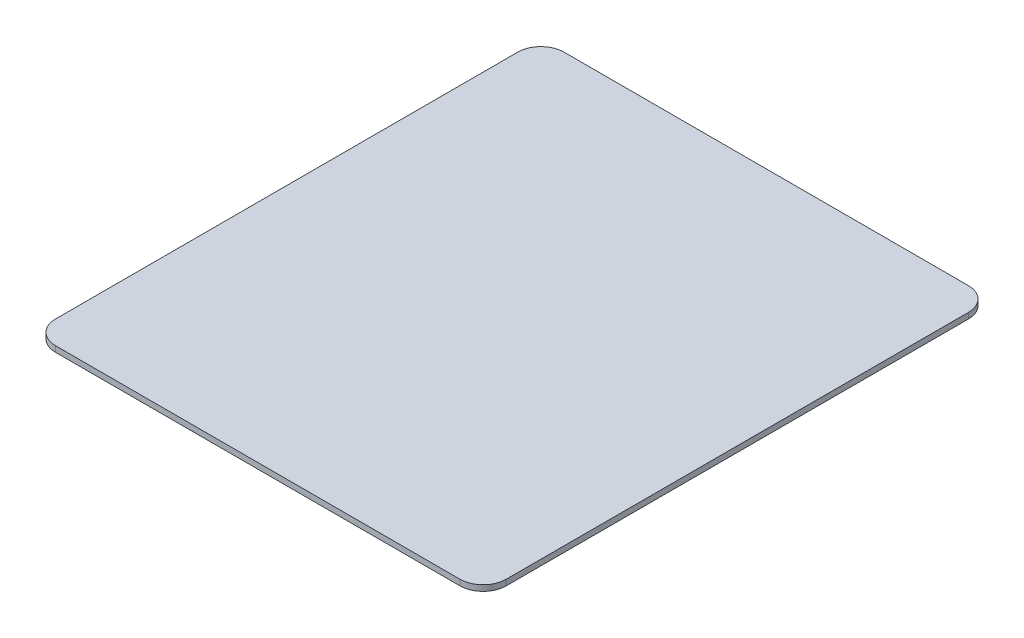
from build123d import *

# Parameters (mm, degrees)
BOSS_EXTRUDE1_DEPTH = 0.5


with BuildPart() as part:
    # Sketch3 → Boss-Extrude1 (new body)
    with BuildSketch(Plane(origin=(0, 0, 0), x_dir=(1, 0, 0), z_dir=(0, 1, 0))):
        with BuildLine():
            Line((-17.5, -22), (17.5, -22))
            ThreePointArc((17.5, -22), (18.914213562, -21.414213562), (19.5, -20))
            Line((19.5, -20), (19.5, 20))
            ThreePointArc((19.5, 20), (18.914213562, 21.414213562), (17.5, 22))
            Line((17.5, 22), (-17.5, 22))
            ThreePointArc((-17.5, 22), (-18.914213562, 21.414213562), (-19.5, 20))
            Line((-19.5, 20), (-19.5, -20))
            ThreePointArc((-19.5, -20), (-18.914213562, -21.414213562), (-17.5, -22))
        make_face()
    extrude(amount=BOSS_EXTRUDE1_DEPTH)


solid = part.part
